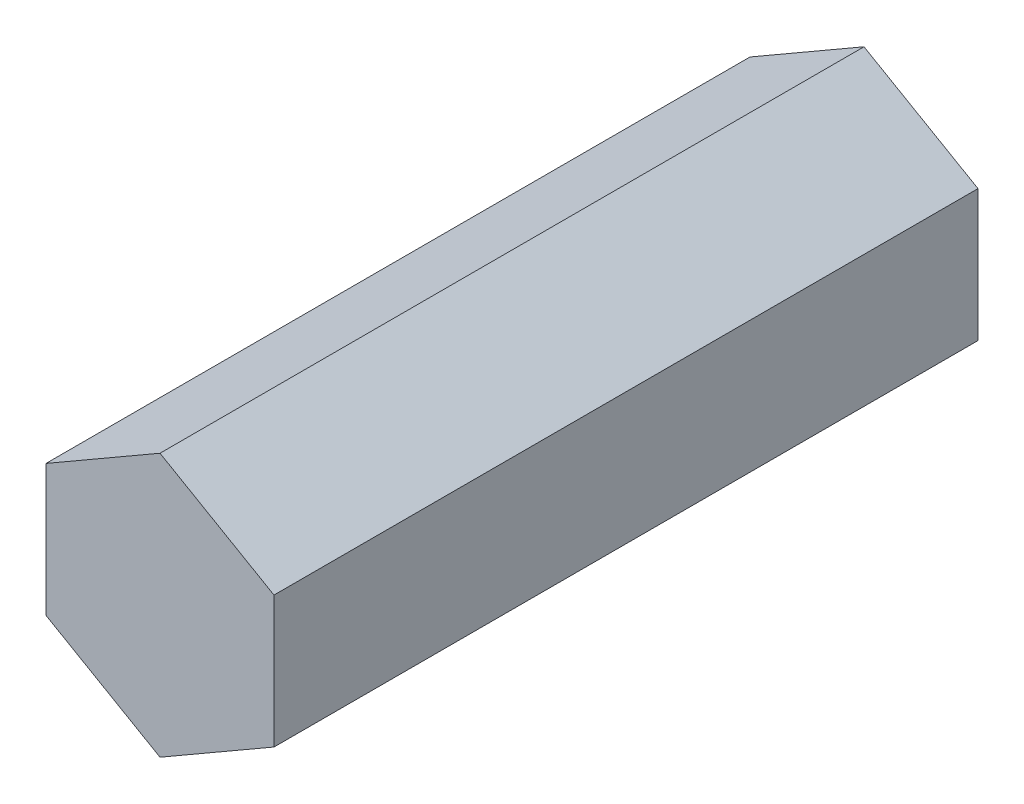
from build123d import *

# Parameters (mm, degrees)
BOSS_EXTRUDE1_DEPTH = 238


with BuildPart() as part:
    # Sketch2 → Boss-Extrude1 (new body, symmetric)
    with BuildSketch(Plane.XY):
        Polygon((0, 89), (-77.076260937, 44.5), (-77.076260937, -44.5), (0, -89), (77.076260937, -44.5), (77.076260937, 44.5), align=None)
    extrude(amount=BOSS_EXTRUDE1_DEPTH, both=True)


solid = part.part
